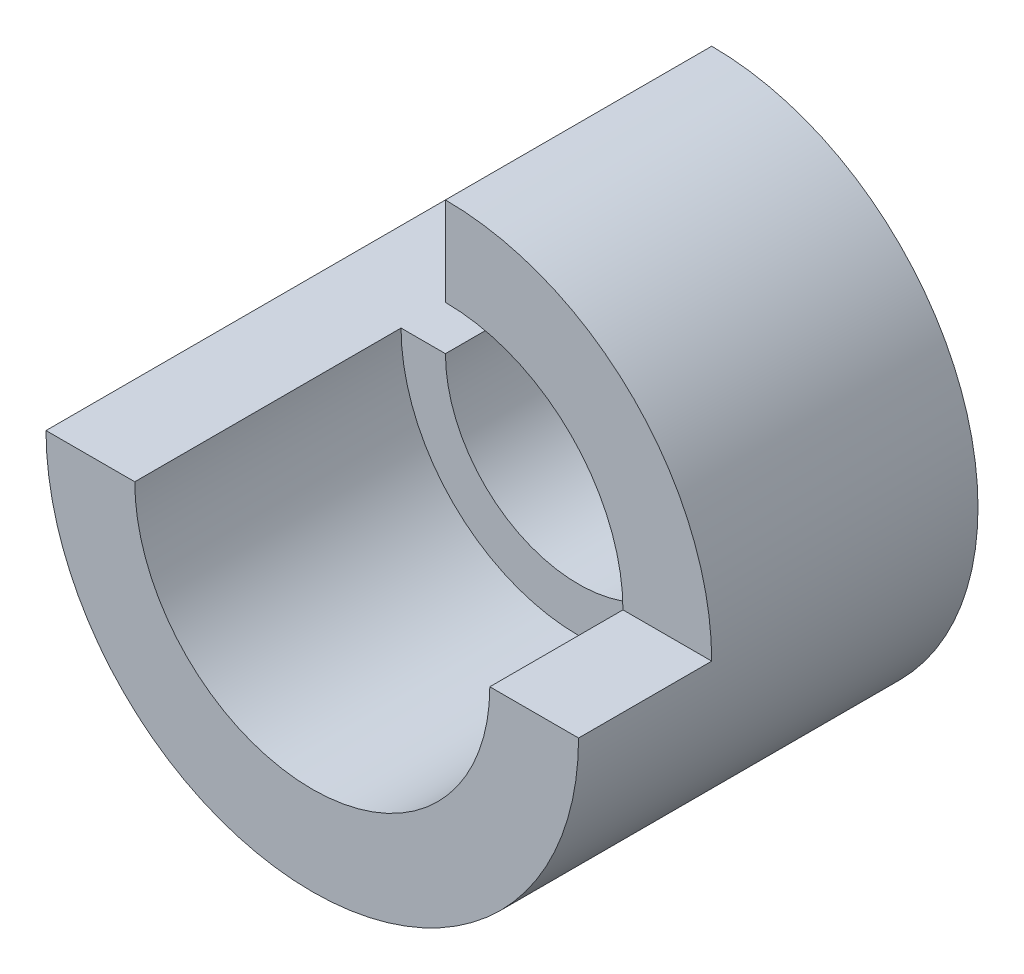
from build123d import *

# Parameters (mm, degrees)
BOSS_EXTRUDE1_DEPTH = 9
SKETCH2_W           = 6
SKETCH2_H           = 6
CUT_EXTRUDE1_DEPTH  = 3
SKETCH3_R           = 4
CUT_EXTRUDE2_DEPTH  = 6


with BuildPart() as part:
    # Sketch1 → Boss-Extrude1 (new body)
    with BuildSketch(Plane.XY):
        with BuildLine():
            Line((-6, 0), (-3, 0))
            ThreePointArc((-3, 0), (2.121320344, -2.121320344), (0, 3))
            Line((0, 3), (0, 6))
            ThreePointArc((0, 6), (4.242640687, -4.242640687), (-6, 0))
        make_face()
    extrude(amount=BOSS_EXTRUDE1_DEPTH)

    # Sketch2 → Cut-Extrude1 (cut)
    with BuildSketch(Plane.XY.offset(9)):
        with Locations((3, 3)):
            Rectangle(SKETCH2_W, SKETCH2_H)
    extrude(amount=-CUT_EXTRUDE1_DEPTH, mode=Mode.SUBTRACT)

    # Sketch3 → Cut-Extrude2 (cut)
    with BuildSketch(Plane.XY.offset(9)):
        Circle(SKETCH3_R)
    extrude(amount=-CUT_EXTRUDE2_DEPTH, mode=Mode.SUBTRACT)


solid = part.part
